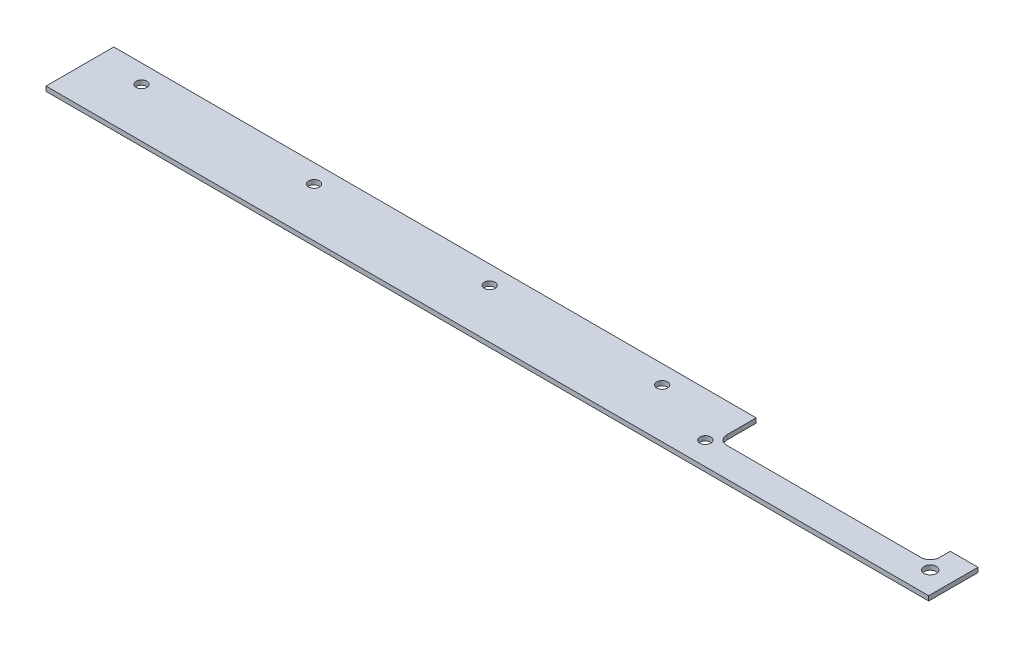
from build123d import *

# Parameters (mm, degrees)
SKETCH_1_R      = 1.75
SKETCH_1_R_2    = 2
EXTRUDE_1_DEPTH = 1.5


with BuildPart() as part:
    # Эскиз1 → Бобышка-Вытянуть1 (new body)
    with BuildSketch(Plane(origin=(0, 0, 0), x_dir=(1, 0, 0), z_dir=(0, 1, 0))):
        with BuildLine():
            Line((208.5, 12.5), (208.5, 22))
            Line((208.5, 22), (0, 22))
            Line((0, 22), (0, 0))
            Line((0, 0), (286.5, 0))
            Line((286.5, 0), (286.5, 16))
            Line((286.5, 16), (277.5, 16))
            Line((277.5, 16), (277.5, 12.5))
            ThreePointArc((277.5, 12.5), (276.621320344, 10.378679656), (274.5, 9.5))
            Line((274.5, 9.5), (211.5, 9.5))
            ThreePointArc((211.5, 9.5), (209.378679656, 10.378679656), (208.5, 12.5))
        make_face()
        with Locations((206.5, 7.5)):
            Circle(SKETCH_1_R, mode=Mode.SUBTRACT)
        with Locations((279.5, 7.5)):
            Circle(SKETCH_1_R_2, mode=Mode.SUBTRACT)
        with Locations((15, 16)):
            Circle(SKETCH_1_R, mode=Mode.SUBTRACT)
        with Locations((71, 16)):
            Circle(SKETCH_1_R, mode=Mode.SUBTRACT)
        with Locations((128, 16)):
            Circle(SKETCH_1_R, mode=Mode.SUBTRACT)
        with Locations((184, 16)):
            Circle(SKETCH_1_R, mode=Mode.SUBTRACT)
    extrude(amount=EXTRUDE_1_DEPTH)


solid = part.part
